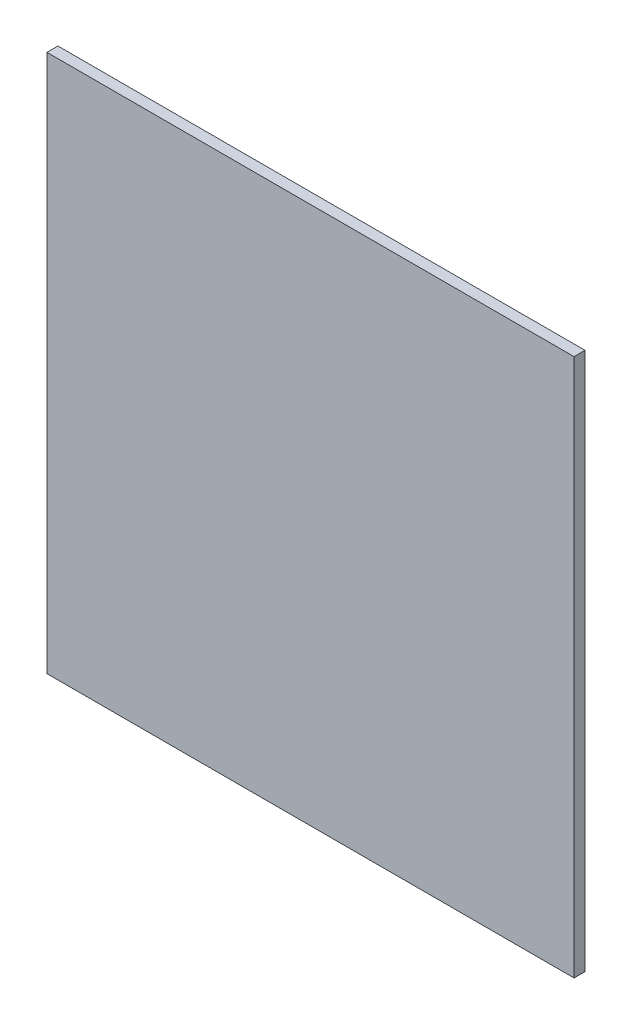
from build123d import *

# Parameters (mm, degrees)
SKETCH1_W           = 240
SKETCH1_H           = 410
BOSS_EXTRUDE1_DEPTH = 5
SKETCH2_W           = 240
SKETCH2_H           = 5
CUT_EXTRUDE1_DEPTH  = 165


with BuildPart() as part:
    # Sketch1 → Boss-Extrude1 (new body)
    with BuildSketch(Plane.XY):
        with Locations((120, -205)):
            Rectangle(SKETCH1_W, SKETCH1_H)
    extrude(amount=BOSS_EXTRUDE1_DEPTH)

    # Sketch2 → Cut-Extrude1 (cut)
    with BuildSketch(Plane.XZ.offset(410)):
        with Locations((120, 2.5)):
            Rectangle(SKETCH2_W, SKETCH2_H)
    extrude(amount=-CUT_EXTRUDE1_DEPTH, mode=Mode.SUBTRACT)


solid = part.part
